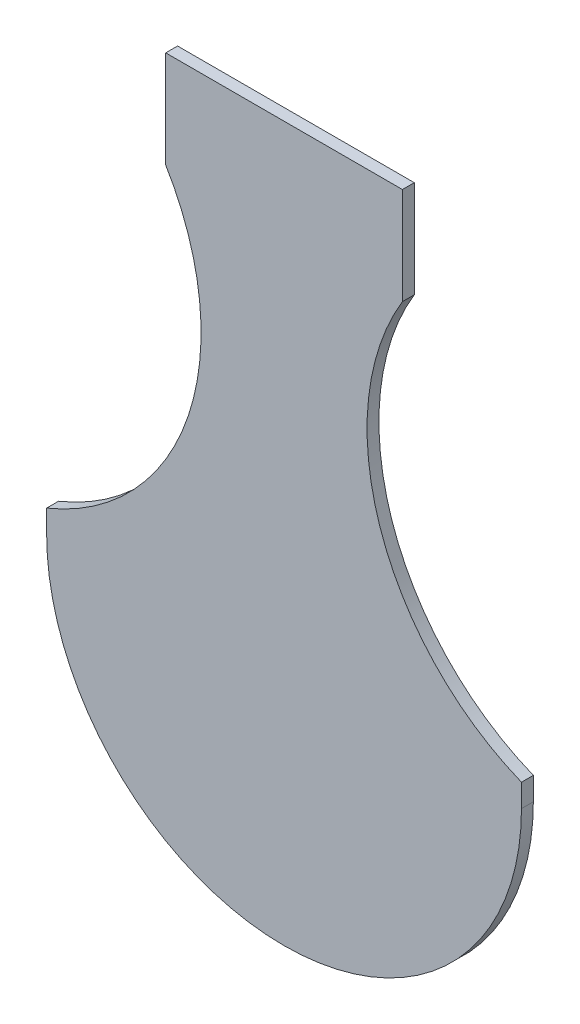
from build123d import *

# Parameters (mm, degrees)
BOSS_EXTRUDE1_DEPTH = 3
CUT_EXTRUDE1_DEPTH  = 4


with BuildPart() as part:
    # Sketch1 → Boss-Extrude1 (new body)
    with BuildSketch(Plane.XY):
        with BuildLine():
            Line((60, 65.779396594), (60, 0))
            Line((60, 0), (-60, 0))
            Line((-60, 0), (-60, 65.779396594))
            ThreePointArc((-60, 65.779396594), (-24.19023261, 103.91162188), (-29.909652169, 155.908682236))
            Line((-29.909652169, 155.908682236), (-29.909652169, 180.455528653))
            Line((-29.909652169, 180.455528653), (29.909652169, 180.455528653))
            Line((29.909652169, 180.455528653), (29.909652169, 155.908682236))
            ThreePointArc((29.909652169, 155.908682236), (24.19023261, 103.91162188), (60, 65.779396594))
        make_face()
    extrude(amount=BOSS_EXTRUDE1_DEPTH)

    # Sketch2 → Cut-Extrude1 (cut, through all)
    with BuildSketch(Plane.XY.offset(3)):
        with BuildLine():
            Line((-60, 60), (-60, -14.155296416))
            Line((-60, -14.155296416), (60, -14.155296416))
            Line((60, -14.155296416), (60, 60))
            ThreePointArc((60, 60), (0, 0), (-60, 60))
        make_face()
    extrude(amount=-CUT_EXTRUDE1_DEPTH, mode=Mode.SUBTRACT)


solid = part.part
